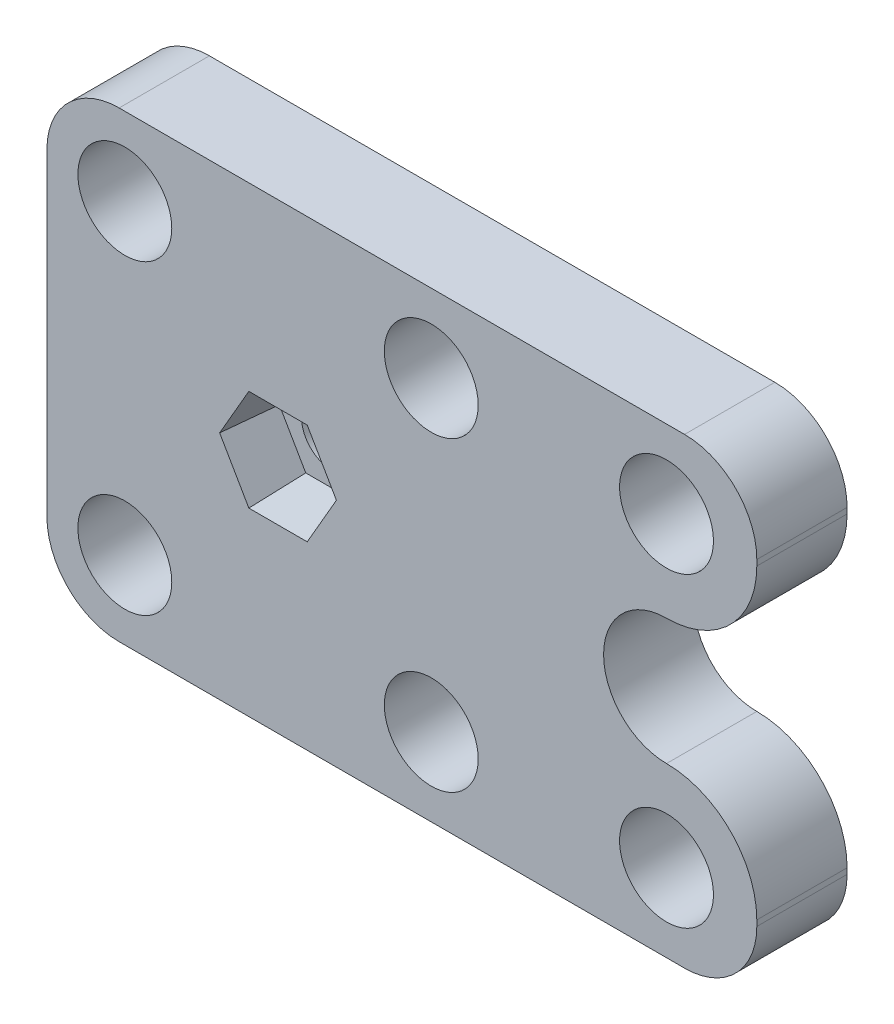
from build123d import *

# Parameters (mm, degrees)
ESQUISSE1_R             = 1.7
ESQUISSE1_R_2           = 2.6
BOSS_EXTRU_1_DEPTH      = 5
ENL_V_MAT_EXTRU_1_DEPTH = 3
ENL_V_MAT_EXTRU_1_TAPER = 5
CONG_1_R                = 4


with BuildPart() as part:
    # Esquisse1 → Boss.-Extru.1 (new body)
    with BuildSketch(Plane.XY):
        with BuildLine():
            Line((-12.8, -12.8), (12.8, -12.8))
            Line((12.8, -12.8), (26.514718626, -12.8))
            Line((26.514718626, -12.8), (26.514718626, -8.485281374))
            ThreePointArc((26.514718626, -8.485281374), (25.050252532, -4.949747468), (21.514718626, -3.485281374))
            ThreePointArc((21.514718626, -3.485281374), (18.029437252, 0), (21.514718626, 3.485281374))
            ThreePointArc((21.514718626, 3.485281374), (25.050252532, 4.949747468), (26.514718626, 8.485281374))
            Line((26.514718626, 8.485281374), (26.514718626, 12.8))
            Line((26.514718626, 12.8), (12.8, 12.8))
            Line((12.8, 12.8), (-12.8, 12.8))
            Line((-12.8, 12.8), (-12.8, -12.8))
        make_face()
        Circle(ESQUISSE1_R, mode=Mode.SUBTRACT)
        with Locations((-8.485281374, 8.485281374)):
            Circle(ESQUISSE1_R_2, mode=Mode.SUBTRACT)
        with Locations((8.485281374, 8.485281374)):
            Circle(ESQUISSE1_R_2, mode=Mode.SUBTRACT)
        with Locations((8.485281374, -8.485281374)):
            Circle(ESQUISSE1_R_2, mode=Mode.SUBTRACT)
        with Locations((-8.485281374, -8.485281374)):
            Circle(ESQUISSE1_R_2, mode=Mode.SUBTRACT)
        with Locations((21.514718626, -8.485281374)):
            Circle(ESQUISSE1_R_2, mode=Mode.SUBTRACT)
        with Locations((21.514718626, 8.485281374)):
            Circle(ESQUISSE1_R_2, mode=Mode.SUBTRACT)
    extrude(amount=BOSS_EXTRU_1_DEPTH)

    # Esquisse2 → Enlèv. mat.-Extru.1 (cut)
    with BuildSketch(Plane.XY.offset(5)):
        Polygon((3.233161507, 0), (1.616580754, 2.8), (-1.616580754, 2.8), (-3.233161507, 0), (-1.616580754, -2.8), (1.616580754, -2.8), align=None)
    extrude(amount=-ENL_V_MAT_EXTRU_1_DEPTH, taper=ENL_V_MAT_EXTRU_1_TAPER, mode=Mode.SUBTRACT)

    # Congé1
    cong_1_edges = [part.edges().sort_by_distance(p)[0] for p in [
        (26.514718626, 12.8, 2.5),
        (26.514718626, -12.8, 2.5),
        (-12.8, -12.8, 2.5),
        (-12.8, 12.8, 2.5),
    ]]
    fillet(cong_1_edges, radius=CONG_1_R)


solid = part.part
